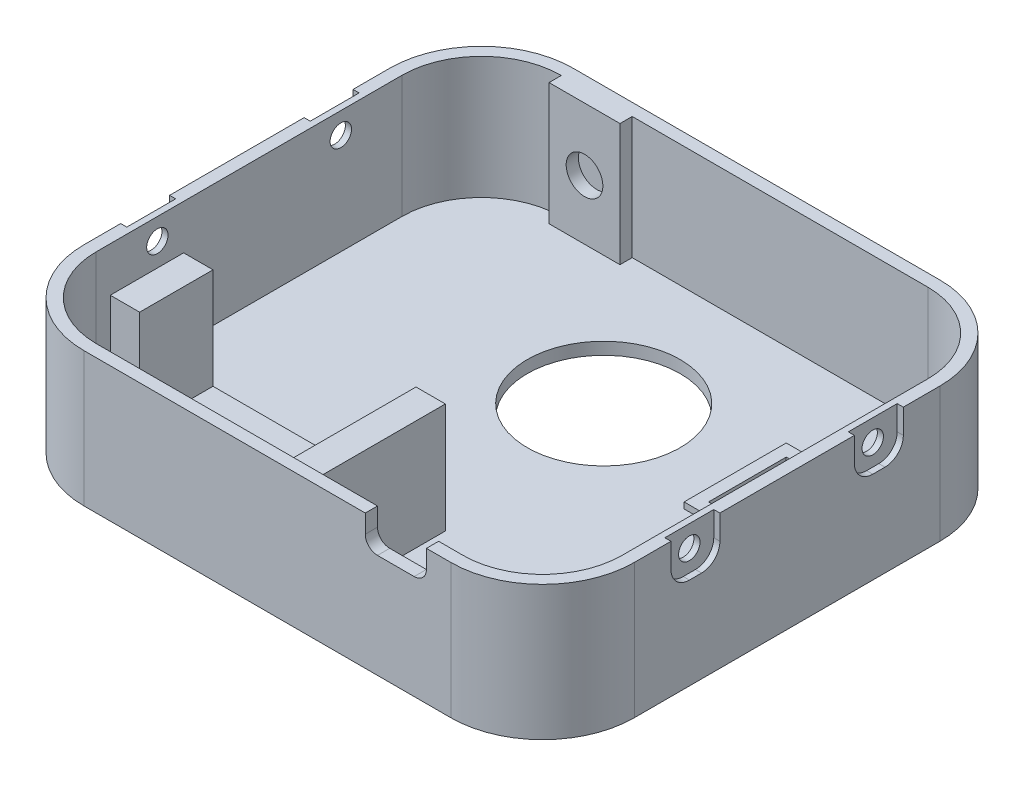
from build123d import *

# Parameters (mm, degrees)
BOSS_EXTRUDE1_DEPTH = 2
BOSS_EXTRUDE2_DEPTH = 20
SKETCH3_R           = 12.5
CUT_EXTRUDE2_DEPTH  = 23
BOSS_EXTRUDE3_DEPTH = 1.5
SKETCH6_W           = 17.4
SKETCH6_H           = 16.7
SKETCH6_W_2         = 13.4
SKETCH6_H_2         = 12.7
BOSS_EXTRUDE4_DEPTH = 1
SKETCH7_W           = 11.6
SKETCH7_H           = 20
SKETCH7_R           = 3
BOSS_EXTRUDE5_DEPTH = 2
SKETCH8_W           = 4.8
SKETCH8_H           = 12
SKETCH8_H_2         = 20
BOSS_EXTRUDE6_DEPTH = 16.5
SKETCH9_R           = 0.5
CUT_EXTRUDE3_DEPTH  = 5
CUT_EXTRUDE4_DEPTH  = 2
SKETCH11_R          = 1.75
CUT_EXTRUDE5_DEPTH  = 2
CUT_EXTRUDE6_DEPTH  = 1


with BuildPart() as part:
    # Sketch1 → Boss-Extrude1 (new body)
    with BuildSketch(Plane(origin=(0, 0, 0), x_dir=(1, 0, 0), z_dir=(0, 1, 0))):
        with BuildLine():
            Line((-30, 25), (30, 25))
            ThreePointArc((30, 25), (40.606601718, 20.606601718), (45, 10))
            Line((45, 10), (45, -40))
            ThreePointArc((45, -40), (40.606601718, -50.606601718), (30, -55))
            Line((30, -55), (-30, -55))
            ThreePointArc((-30, -55), (-40.606601718, -50.606601718), (-45, -40))
            Line((-45, -40), (-45, 10))
            ThreePointArc((-45, 10), (-40.606601718, 20.606601718), (-30, 25))
        make_face()
    extrude(amount=BOSS_EXTRUDE1_DEPTH)

    # Sketch4 → Boss-Extrude2 (add)
    with BuildSketch(Plane(origin=(0, 2, 0), x_dir=(1, 0, 0), z_dir=(0, 1, 0))):
        with BuildLine():
            Line((30, 25), (-30, 25))
            ThreePointArc((-30, 25), (-40.606601718, 20.606601718), (-45, 10))
            Line((-45, 10), (-45, -40))
            ThreePointArc((-45, -40), (-40.606601718, -50.606601718), (-30, -55))
            Line((-30, -55), (30, -55))
            ThreePointArc((30, -55), (40.606601718, -50.606601718), (45, -40))
            Line((45, -40), (45, 10))
            ThreePointArc((45, 10), (40.606601718, 20.606601718), (30, 25))
        make_face()
        with BuildLine():
            Line((30, 23), (-30, 23))
            ThreePointArc((-30, 23), (-39.192388155, 19.192388155), (-43, 10))
            Line((-43, 10), (-43, -40))
            ThreePointArc((-43, -40), (-39.192388155, -49.192388155), (-30, -53))
            Line((-30, -53), (30, -53))
            ThreePointArc((30, -53), (39.192388155, -49.192388155), (43, -40))
            Line((43, -40), (43, 10))
            ThreePointArc((43, 10), (39.192388155, 19.192388155), (30, 23))
        make_face(mode=Mode.SUBTRACT)
    extrude(amount=BOSS_EXTRUDE2_DEPTH)

    # Sketch3 → Cut-Extrude2 (cut, through all)
    with BuildSketch(Plane.XZ):
        Circle(SKETCH3_R)
    extrude(amount=-CUT_EXTRUDE2_DEPTH, mode=Mode.SUBTRACT)

    # Sketch5 → Boss-Extrude3 (add)
    with BuildSketch(Plane(origin=(0, 2, 0), x_dir=(1, 0, 0), z_dir=(0, 1, 0))):
        Polygon((-36.002943725, -53), (5.1, -53), (5.1, -31), (-37.7, -31), (-37.7, -51.302943725), align=None)
    extrude(amount=BOSS_EXTRUDE3_DEPTH)

    # Sketch6 → Boss-Extrude4 (add)
    with BuildSketch(Plane(origin=(0, 2, 0), x_dir=(1, 0, 0), z_dir=(0, 1, 0))):
        with Locations((30.2, 0)):
            Rectangle(SKETCH6_W, SKETCH6_H)
        with Locations((30.2, 0)):
            Rectangle(SKETCH6_W_2, SKETCH6_H_2, mode=Mode.SUBTRACT)
    extrude(amount=BOSS_EXTRUDE4_DEPTH)

    # Sketch7 → Boss-Extrude5 (add)
    with BuildSketch(Plane.XY.offset(-23)):
        with Locations((-24.14, 12)):
            Rectangle(SKETCH7_W, SKETCH7_H)
        with Locations((-24.14, 11.75)):
            Circle(SKETCH7_R, mode=Mode.SUBTRACT)
    extrude(amount=BOSS_EXTRUDE5_DEPTH)

    # Sketch8 → Boss-Extrude6 (add)
    with BuildSketch(Plane(origin=(0, 3.5, 0), x_dir=(1, 0, 0), z_dir=(0, 1, 0))):
        with Locations((-35.3, -37)):
            Rectangle(SKETCH8_W, SKETCH8_H)
        with Locations((2.7, -41)):
            Rectangle(SKETCH8_W, SKETCH8_H_2)
    extrude(amount=BOSS_EXTRUDE6_DEPTH)

    # Sketch9 → Cut-Extrude3 (cut)
    with BuildSketch(Plane(origin=(0, 0, 31), x_dir=(-1, 0, 0), z_dir=(0, 0, -1))):
        with Locations((-2.7, 15.75)):
            Circle(SKETCH9_R)
        with Locations((-2.7, 7.75)):
            Circle(SKETCH9_R)
        with Locations((35.3, 15.75)):
            Circle(SKETCH9_R)
        with Locations((35.3, 7.75)):
            Circle(SKETCH9_R)
    extrude(amount=-CUT_EXTRUDE3_DEPTH, mode=Mode.SUBTRACT)

    # Sketch10 → Cut-Extrude4 (cut)
    with BuildSketch(Plane.XY.offset(55)):
        with BuildLine():
            Line((16, 22), (26, 22))
            Line((26, 22), (26, 19))
            ThreePointArc((26, 19), (25.414213562, 17.585786438), (24, 17))
            Line((24, 17), (18, 17))
            ThreePointArc((18, 17), (16.585786438, 17.585786438), (16, 19))
            Line((16, 19), (16, 22))
        make_face()
    extrude(amount=-CUT_EXTRUDE4_DEPTH, mode=Mode.SUBTRACT)

    # Sketch11 → Cut-Extrude5 (cut)
    with BuildSketch(Plane(origin=(-43, 0, 0), x_dir=(0, 0, -1), z_dir=(1, 0, 0))):
        with Locations((-30, 18.5)):
            Circle(SKETCH11_R)
        with Locations((0, 18.5)):
            Circle(SKETCH11_R)
    cut_extrude5 = extrude(amount=-CUT_EXTRUDE5_DEPTH, mode=Mode.SUBTRACT)

    # Sketch12 → Cut-Extrude6 (cut)
    with BuildSketch(Plane.ZY.offset(45)):
        with BuildLine():
            Line((-4, 22), (4, 22))
            Line((4, 22), (4, 18))
            ThreePointArc((4, 18), (3.121320344, 15.878679656), (1, 15))
            Line((1, 15), (-1, 15))
            ThreePointArc((-1, 15), (-3.121320344, 15.878679656), (-4, 18))
            Line((-4, 18), (-4, 22))
        make_face()
        with BuildLine():
            Line((26, 22), (34, 22))
            Line((34, 22), (34, 18))
            ThreePointArc((34, 18), (33.121320344, 15.878679656), (31, 15))
            Line((31, 15), (29, 15))
            ThreePointArc((29, 15), (26.878679656, 15.878679656), (26, 18))
            Line((26, 18), (26, 22))
        make_face()
    cut_extrude6 = extrude(amount=-CUT_EXTRUDE6_DEPTH, mode=Mode.SUBTRACT)

    # Mirror1: Cut-Extrude5, Cut-Extrude6 across plane
    add(cut_extrude5.mirror(Plane(origin=(0, 0, 0), x_dir=(0, 0, 1), z_dir=(1, 0, 0))), mode=Mode.SUBTRACT)
    add(cut_extrude6.mirror(Plane(origin=(0, 0, 0), x_dir=(0, 0, 1), z_dir=(1, 0, 0))), mode=Mode.SUBTRACT)


solid = part.part
